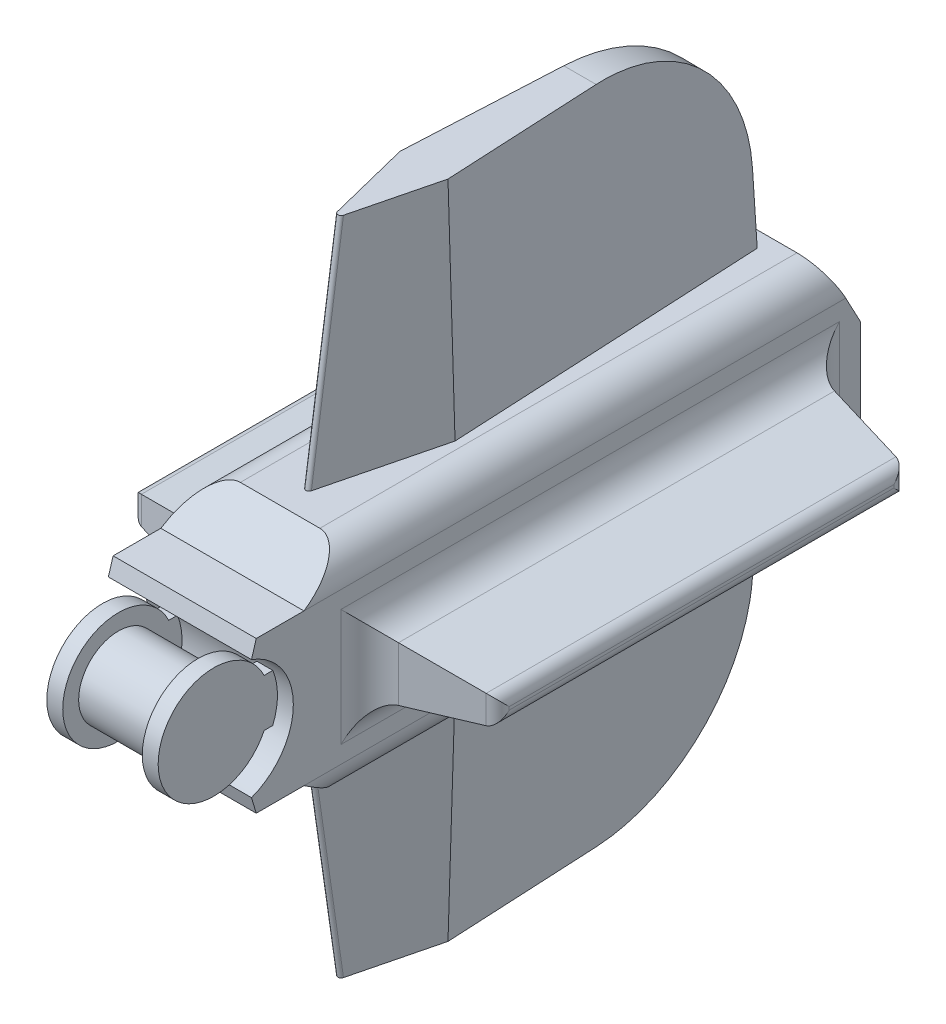
from build123d import *

# Parameters (mm, degrees)
SKETCH1_R                = 3.175
BOSS_EXTRUDE1_DEPTH      = 3.175
SKETCH2_R                = 4.445
BOSS_EXTRUDE2_DEPTH      = 1.27
SKETCH3_W                = 6.35
SKETCH3_H                = 3.81
BOSS_EXTRUDE3_DEPTH      = 1.27
BOSS_EXTRUDE4_DEPTH      = 8.89
BOSS_EXTRUDE4_DEPTH_BACK = 2.54
SKETCH5_R                = 3.175
CUT_EXTRUDE1_DEPTH       = 12.7
FILLET1_R                = 2.54
SKETCH6_W                = 35.56
SKETCH6_H                = 5.08
BOSS_EXTRUDE5_DEPTH      = 8.89
BOSS_EXTRUDE5_TAPER      = 10
FILLET2_R                = 1.016
FILLET3_R                = 2.54
BOSS_EXTRUDE6_DEPTH      = 17.78
BOSS_EXTRUDE6_TAPER      = 2
FILLET4_R                = 0.254
FILLET5_R                = 12.7


with BuildPart() as part:
    # Sketch1 → Boss-Extrude1 (new body, symmetric)
    with BuildSketch(Plane(origin=(0, 0, 0), x_dir=(0, 0, -1), z_dir=(1, 0, 0))):
        Circle(SKETCH1_R)
    extrude(amount=BOSS_EXTRUDE1_DEPTH, both=True)

    # Sketch2 → Boss-Extrude2 (add)
    with BuildSketch(Plane(origin=(3.175, 0, 0), x_dir=(0, 0, -1), z_dir=(1, 0, 0))):
        Circle(SKETCH2_R)
    boss_extrude2 = extrude(amount=BOSS_EXTRUDE2_DEPTH)

    # Mirror1: Boss-Extrude2 across plane
    add(boss_extrude2.mirror(Plane(origin=(0, 0, 0), x_dir=(0, 0, 1), z_dir=(1, 0, 0))))

    # Sketch3 → Boss-Extrude3 (add)
    with BuildSketch(Plane(origin=(4.445, 0, 0), x_dir=(0, 0, -1), z_dir=(1, 0, 0))):
        with Locations((3.175, 0)):
            Rectangle(SKETCH3_W, SKETCH3_H)
    boss_extrude3 = extrude(amount=-BOSS_EXTRUDE3_DEPTH)

    # Mirror2: Boss-Extrude3 across plane
    add(boss_extrude3.mirror(Plane(origin=(0, 0, 0), x_dir=(0, 0, 1), z_dir=(1, 0, 0))))

    # Sketch4 → Boss-Extrude4 (add, two sides)
    with BuildSketch(Plane(origin=(-3.175, 0, 0), x_dir=(0, 0, -1), z_dir=(1, 0, 0))) as boss_extrude4_sk:
        with BuildLine():
            Line((1.737462328, 4.773638514), (2.118462328, 6.043638514))
            Line((2.118462328, 6.043638514), (5.928462328, 6.043638514))
            Line((5.928462328, 6.043638514), (9.738462328, 8.583638514))
            Line((9.738462328, 8.583638514), (47.838462328, 8.583638514))
            Line((47.838462328, 8.583638514), (50.378462328, 3.81))
            Line((50.378462328, 3.81), (50.378462328, -3.81))
            Line((50.378462328, -3.81), (47.838462328, -8.583638514))
            Line((47.838462328, -8.583638514), (9.738462328, -8.583638514))
            Line((9.738462328, -8.583638514), (5.928462328, -6.043638514))
            Line((5.928462328, -6.043638514), (2.118462328, -6.043638514))
            Line((2.118462328, -6.043638514), (1.737462328, -4.773638514))
            ThreePointArc((1.737462328, -4.773638514), (5.08, 0), (1.737462328, 4.773638514))
        make_face()
    extrude(amount=BOSS_EXTRUDE4_DEPTH)
    extrude(boss_extrude4_sk.sketch, amount=-BOSS_EXTRUDE4_DEPTH_BACK)

    # Sketch5 → Cut-Extrude1 (cut)
    with BuildSketch(Plane(origin=(0, 0, -50.378462328), x_dir=(-1, 0, 0), z_dir=(0, 0, -1))):
        Circle(SKETCH5_R)
    extrude(amount=-CUT_EXTRUDE1_DEPTH, mode=Mode.SUBTRACT)

    # Fillet1
    fillet1_edges = [part.edges().sort_by_distance(p)[0] for p in [
        (5.715, -8.583638514, -28.788462328),
        (-5.715, -8.583638514, -28.788462328),
        (-5.715, 8.583638514, -28.788462328),
        (5.715, 8.583638514, -28.788462328),
    ]]
    fillet(fillet1_edges, radius=FILLET1_R)

    # Sketch6 → Boss-Extrude5 (add)
    with BuildSketch(Plane(origin=(5.715, 0, 0), x_dir=(0, 0, -1), z_dir=(1, 0, 0))):
        with Locations((28.788462328, 0)):
            Rectangle(SKETCH6_W, SKETCH6_H)
    boss_extrude5 = extrude(amount=BOSS_EXTRUDE5_DEPTH, taper=BOSS_EXTRUDE5_TAPER)

    # Mirror3: Boss-Extrude5 across plane
    add(boss_extrude5.mirror(Plane(origin=(0, 0, 0), x_dir=(0, 0, 1), z_dir=(1, 0, 0))))

    # Fillet2
    fillet2_edges = [part.edges().sort_by_distance(p)[0] for p in [
        (14.605, 0, -12.576009187),
        (14.605, -0.972453142, -28.788462328),
        (14.605, 0, -45.00091547),
        (14.605, 0.972453142, -28.788462328),
        (-14.605, 0, -12.576009187),
        (-14.605, 0.972453142, -28.788462328),
        (-14.605, 0, -45.00091547),
        (-14.605, -0.972453142, -28.788462328),
    ]]
    fillet(fillet2_edges, radius=FILLET2_R)

    # Fillet3
    fillet3_edges = [part.edges().sort_by_distance(p)[0] for p in [
        (5.715, 0, -11.008462328),
        (5.715, -2.54, -28.788462328),
        (5.715, 0, -46.568462328),
        (5.715, 2.54, -28.788462328),
        (-5.715, 0, -11.008462328),
        (-5.715, -2.54, -28.788462328),
        (-5.715, 0, -46.568462328),
        (-5.715, 2.54, -28.788462328),
    ]]
    fillet(fillet3_edges, radius=FILLET3_R)

    # Sketch7 → Boss-Extrude6 (add)
    with BuildSketch(Plane(origin=(0, 8.583638514, 0), x_dir=(1, 0, 0), z_dir=(0, 1, 0))):
        Polygon((-1.27, 46.568462328), (-2.54, 21.168462328), (0, 11.008462328), (2.54, 21.168462328), (1.27, 46.568462328), align=None)
    boss_extrude6 = extrude(amount=BOSS_EXTRUDE6_DEPTH, taper=BOSS_EXTRUDE6_TAPER)

    # Mirror4: Boss-Extrude6 across plane
    add(boss_extrude6.mirror(Plane.ZX))

    # Fillet4
    fillet4_edges = [part.edges().sort_by_distance(p)[0] for p in [
        (0, 17.473638514, -12.288462496),
        (0, -17.473638514, -12.288462496),
    ]]
    fillet(fillet4_edges, radius=FILLET4_R)

    # Fillet5
    fillet5_edges = [part.edges().sort_by_distance(p)[0] for p in [
        (0, 26.363638514, -45.947571047),
        (0, -26.363638514, -45.947571047),
    ]]
    fillet(fillet5_edges, radius=FILLET5_R)


solid = part.part
